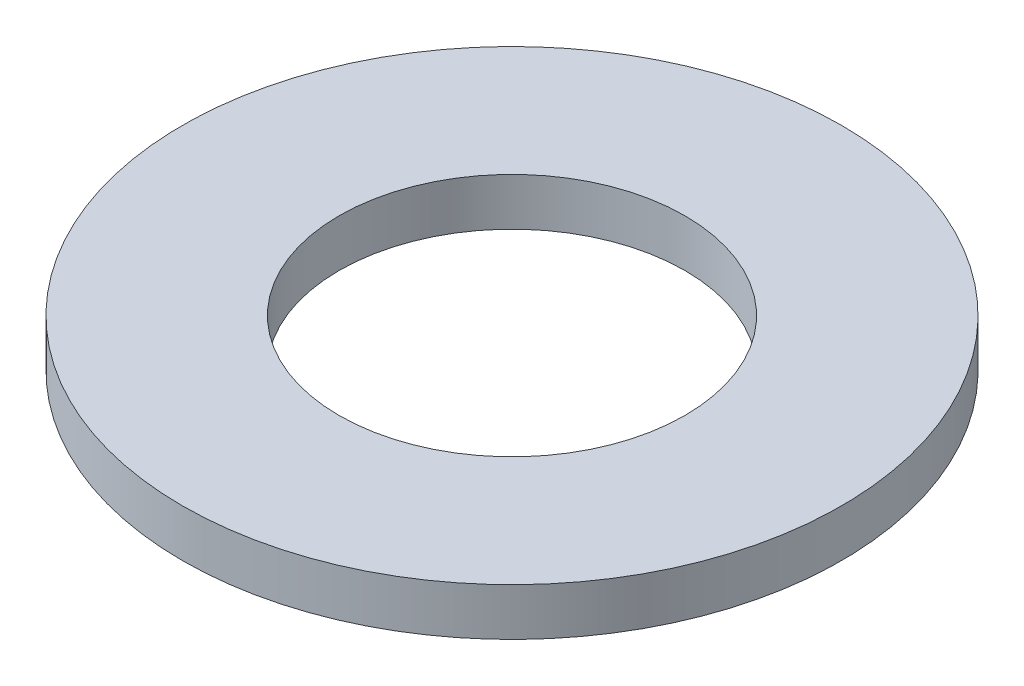
from build123d import *

# Parameters (mm, degrees)
SKETCH1_W = 7.5438
SKETCH1_H = 2.286


with BuildPart() as part:
    # Sketch1 → Revolve1 (revolve)
    with BuildSketch(Plane(origin=(0, 0, 0), x_dir=(-1, 0, 0), z_dir=(0, 0, -1))):
        with Locations((-12.1031, 1.143)):
            Rectangle(SKETCH1_W, SKETCH1_H)
    revolve(axis=Axis((0, 0, 0), (0, 1, 0)))


solid = part.part
